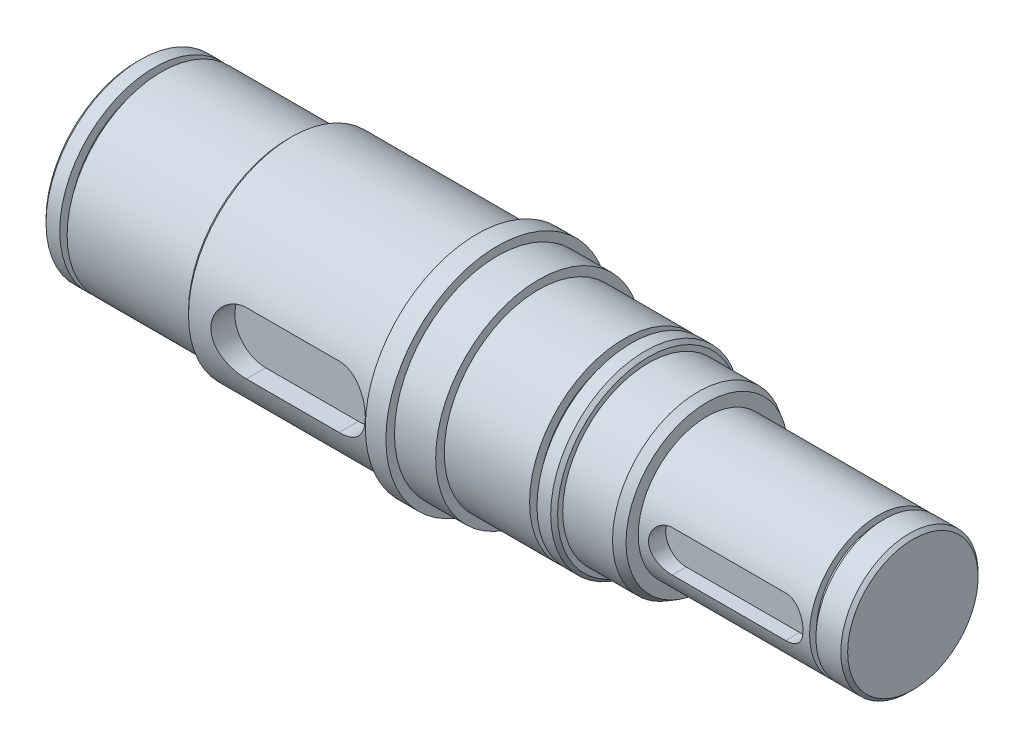
from build123d import *

# Parameters (mm, degrees)
SCHNITT_LINEAR_AUSTRAGEN1_DEPTH = 7
SCHNITT_LINEAR_AUSTRAGEN2_DEPTH = 5


with BuildPart() as part:
    # Skizze1 → Rotation17 (revolve)
    with BuildSketch(Plane.XY, mode=Mode.PRIVATE) as rotation17_sk:
        Polygon((168.152402442, 0), (168.152402442, 26.5), (169.152402442, 27.5), (184.152402442, 27.5), (212.152402442, 27.5), (212.152402442, 29), (213.152402442, 30), (267.152402442, 30), (267.152402442, 32.5), (273.152402442, 32.5), (273.152402442, 30), (285.152402442, 30), (285.152402442, 27.5), (297.652402442, 27.5), (316.152402442, 27.5), (317.152402442, 26.5), (317.152402442, 25), (331.652402442, 25), (334.152402442, 23.556624327), (334.152402442, 20), (393.152402442, 20), (394.152402442, 19), (394.152402442, 0), align=None)
    revolve(rotation17_sk.sketch.rotate(Axis((168.152402442, 0, 0), (1, 0, 0)), 90), axis=Axis((168.152402442, 0, 0), (1, 0, 0)))  # turned: the seam where the file's is

    # Skizze3 → Schnitt-Linear austragen1 (cut)
    with BuildSketch(Plane.XY.offset(30)):
        with BuildLine():
            Line((228.652402442, 9), (255.652402442, 9))
            ThreePointArc((255.652402442, 9), (264.652402442, 0), (255.652402442, -9))
            Line((255.652402442, -9), (228.652402442, -9))
            ThreePointArc((228.652402442, -9), (219.652402442, 0), (228.652402442, 9))
        make_face()
    extrude(amount=-SCHNITT_LINEAR_AUSTRAGEN1_DEPTH, mode=Mode.SUBTRACT)

    # Skizze4 → Schnitt-Linear austragen2 (cut)
    with BuildSketch(Plane.XY.offset(20)):
        with BuildLine():
            Line((343.152402442, 6), (376.152402442, 6))
            ThreePointArc((376.152402442, 6), (382.152402442, 0), (376.152402442, -6))
            Line((376.152402442, -6), (343.152402442, -6))
            ThreePointArc((343.152402442, -6), (337.152402442, 0), (343.152402442, 6))
        make_face()
    extrude(amount=-SCHNITT_LINEAR_AUSTRAGEN2_DEPTH, mode=Mode.SUBTRACT)

    # Skizze16 → Nut f_r DIN 472 - 55 x 2_ Sicherungsring (revolve, cut)
    with BuildSketch(Plane(origin=(168.152402442, 0, 0), x_dir=(0, 0, 1), z_dir=(0, -1, 0))):
        with BuildLine():
            Line((28.785, -7.15), (24.75, -7.15))
            Line((24.75, -7.15), (24.75, -5))
            Line((24.75, -5), (28.785, -5))
            ThreePointArc((28.785, -5), (28.937027958, -5.062972042), (29, -5.215))
            Line((29, -5.215), (29, -6.935))
            ThreePointArc((29, -6.935), (28.937027958, -7.087027958), (28.785, -7.15))
        make_face()
    revolve(axis=Axis((218.152402442, 0, 0), (-1, 0, 0)), mode=Mode.SUBTRACT)

    # Skizze18 → Nut für DIN 472 - 40 x 1.75, Sicherungsring für Bohrungen - Regelausf.1 (revolve, cut)
    with BuildSketch(Plane(origin=(168.152402442, 0, 0), x_dir=(0, 0, 1), z_dir=(0, -1, 0))):
        with BuildLine():
            Line((21.065, -217.75), (18, -217.75))
            Line((18, -217.75), (18, -215.9))
            Line((18, -215.9), (21.065, -215.9))
            ThreePointArc((21.065, -215.9), (21.195814755, -215.954185245), (21.25, -216.085))
            Line((21.25, -216.085), (21.25, -217.565))
            ThreePointArc((21.25, -217.565), (21.195814755, -217.695814755), (21.065, -217.75))
        make_face()
    revolve(axis=Axis((218.152402442, 0, 0), (-1, 0, 0)), mode=Mode.SUBTRACT)

    # Skizze20 → Nut f_r DIN 472 - 55 x 2_ Sicherungs 2 (revolve, cut)
    with BuildSketch(Plane(origin=(168.152402442, 0, 0), x_dir=(0, 0, 1), z_dir=(0, -1, 0))):
        with BuildLine():
            Line((28.785, -144), (24.75, -144))
            Line((24.75, -144), (24.75, -141.85))
            Line((24.75, -141.85), (28.785, -141.85))
            ThreePointArc((28.785, -141.85), (28.937027958, -141.912972042), (29, -142.065))
            Line((29, -142.065), (29, -143.785))
            ThreePointArc((29, -143.785), (28.937027958, -143.937027958), (28.785, -144))
        make_face()
    revolve(axis=Axis((218.152402442, 0, 0), (-1, 0, 0)), mode=Mode.SUBTRACT)


solid = part.part
